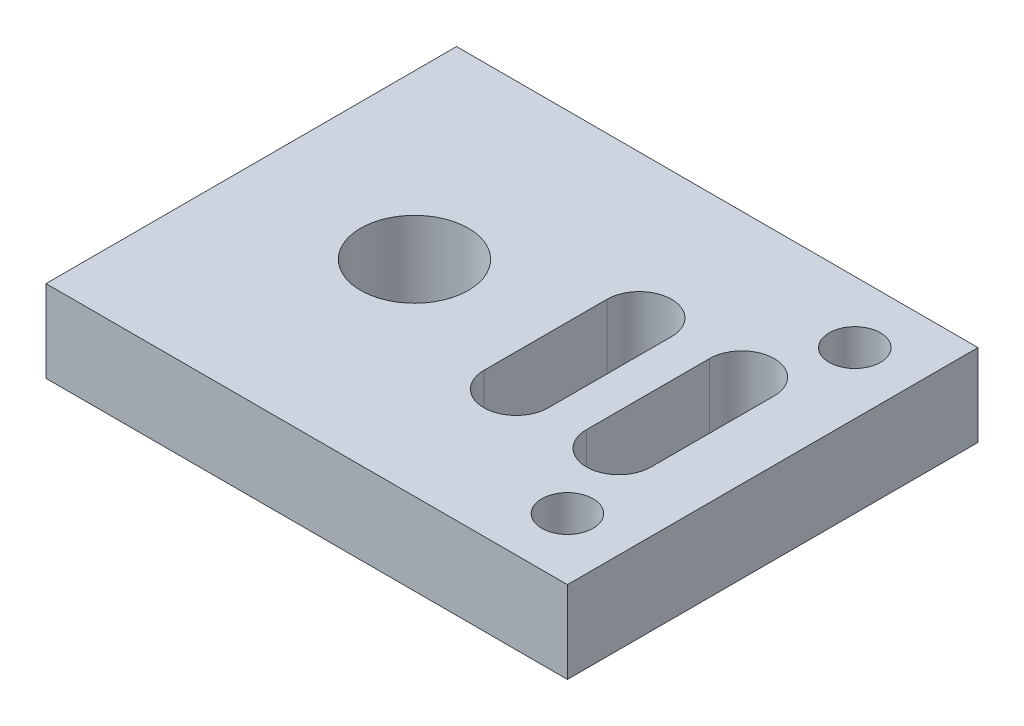
from build123d import *

# Parameters (mm, degrees)
SKETCH1_W           = 25.4
SKETCH1_H           = 20
SKETCH1_R           = 1.25
SKETCH1_R_2         = 2.625
BOSS_EXTRUDE1_DEPTH = 4


with BuildPart() as part:
    # Sketch1 → Boss-Extrude1 (new body)
    with BuildSketch(Plane(origin=(0, 0, 0), x_dir=(1, 0, 0), z_dir=(0, 1, 0))):
        with Locations((12.7, 10)):
            Rectangle(SKETCH1_W, SKETCH1_H)
        with Locations((22.4, 17)):
            Circle(SKETCH1_R, mode=Mode.SUBTRACT)
        with Locations((7.95, 10)):
            Circle(SKETCH1_R_2, mode=Mode.SUBTRACT)
        with Locations((22.4, 3)):
            Circle(SKETCH1_R, mode=Mode.SUBTRACT)
        with BuildLine():
            Line((19.325, 7), (19.325, 13))
            ThreePointArc((19.325, 13), (20.9, 14.575), (22.475, 13))
            Line((22.475, 13), (22.475, 7))
            ThreePointArc((22.475, 7), (20.9, 5.425), (19.325, 7))
        make_face(mode=Mode.SUBTRACT)
        with BuildLine():
            Line((14.325, 7), (14.325, 13))
            ThreePointArc((14.325, 13), (15.9, 14.575), (17.475, 13))
            Line((17.475, 13), (17.475, 7))
            ThreePointArc((17.475, 7), (15.9, 5.425), (14.325, 7))
        make_face(mode=Mode.SUBTRACT)
    extrude(amount=-BOSS_EXTRUDE1_DEPTH)


solid = part.part
